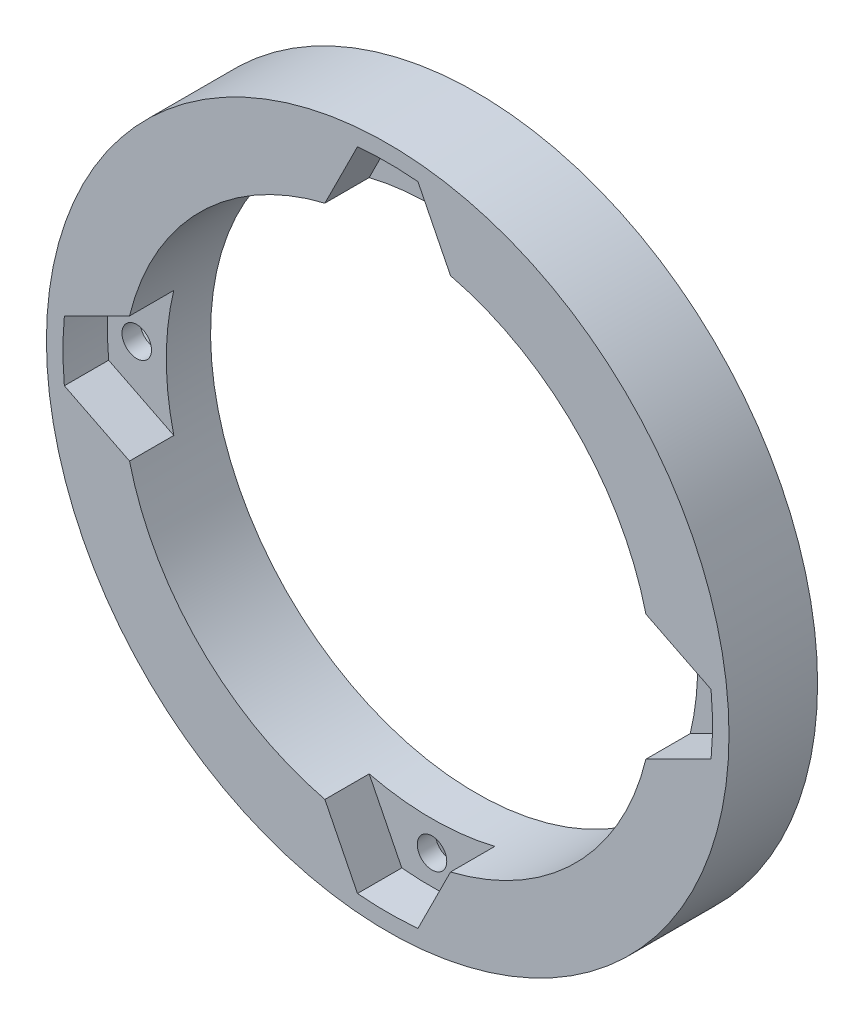
from build123d import *

# Parameters (mm, degrees)
SKETCH2_R           = 73.406
SKETCH2_R_2         = 57.15
BOSS_EXTRUDE1_DEPTH = 19.05
CUT_EXTRUDE5_DEPTH  = 9.525
SKETCH9_R           = 3.175
CUT_EXTRUDE6_DEPTH  = 9.525
CUT_EXTRUDE7_DEPTH  = 5.588


with BuildPart() as part:
    # Sketch2 → Boss-Extrude1 (new body)
    with BuildSketch(Plane.XY):
        Circle(SKETCH2_R)
        Circle(SKETCH2_R_2, mode=Mode.SUBTRACT)
    extrude(amount=BOSS_EXTRUDE1_DEPTH)

    # Sketch7 → Cut-Extrude5 (cut)
    with BuildSketch(Plane.XY.offset(19.05)):
        with BuildLine():
            Line((-69.546757065, 6.501621467), (-55.530220399, 13.5098898))
            ThreePointArc((-55.530220399, 13.5098898), (-57.15, 0), (-55.530220399, -13.5098898))
            Line((-55.530220399, -13.5098898), (-69.546757065, -6.501621467))
            ThreePointArc((-69.546757065, -6.501621467), (-69.85, 0), (-69.546757065, 6.501621467))
        make_face()
        with BuildLine():
            Line((6.501621467, 69.546757065), (13.5098898, 55.530220399))
            ThreePointArc((13.5098898, 55.530220399), (0, 57.15), (-13.5098898, 55.530220399))
            Line((-13.5098898, 55.530220399), (-6.501621467, 69.546757065))
            ThreePointArc((-6.501621467, 69.546757065), (0, 69.85), (6.501621467, 69.546757065))
        make_face()
        with BuildLine():
            Line((69.546757065, -6.501621467), (55.530220399, -13.5098898))
            ThreePointArc((55.530220399, -13.5098898), (57.15, 0), (55.530220399, 13.5098898))
            Line((55.530220399, 13.5098898), (69.546757065, 6.501621467))
            ThreePointArc((69.546757065, 6.501621467), (69.85, 0), (69.546757065, -6.501621467))
        make_face()
        with BuildLine():
            Line((-6.501621467, -69.546757065), (-13.5098898, -55.530220399))
            ThreePointArc((-13.5098898, -55.530220399), (0, -57.15), (13.5098898, -55.530220399))
            Line((13.5098898, -55.530220399), (6.501621467, -69.546757065))
            ThreePointArc((6.501621467, -69.546757065), (0, -69.85), (-6.501621467, -69.546757065))
        make_face()
    extrude(amount=-CUT_EXTRUDE5_DEPTH, mode=Mode.SUBTRACT)

    # Sketch9 → Cut-Extrude6 (cut)
    with BuildSketch(Plane.XY.offset(9.525)):
        with Locations((-63.5, 0)):
            Circle(SKETCH9_R)
        with Locations((0, 63.5)):
            Circle(SKETCH9_R)
        with Locations((63.5, 0)):
            Circle(SKETCH9_R)
        with Locations((0, -63.5)):
            Circle(SKETCH9_R)
    extrude(amount=-CUT_EXTRUDE6_DEPTH, mode=Mode.SUBTRACT)

    # Sketch10 → Cut-Extrude7 (cut)
    with BuildSketch(Plane(origin=(0, 0, 0), x_dir=(-1, 0, 0), z_dir=(0, 0, -1))):
        Polygon((-6.30581964, 63.5), (-3.15290982, 58.039), (3.15290982, 58.039), (6.30581964, 63.5), (3.15290982, 68.961), (-3.15290982, 68.961), align=None)
        Polygon((-63.5, -6.30581964), (-58.039, -3.15290982), (-58.039, 3.15290982), (-63.5, 6.30581964), (-68.961, 3.15290982), (-68.961, -3.15290982), align=None)
        Polygon((63.5, 6.30581964), (58.039, 3.15290982), (58.039, -3.15290982), (63.5, -6.30581964), (68.961, -3.15290982), (68.961, 3.15290982), align=None)
        Polygon((6.30581964, -63.5), (3.15290982, -58.039), (-3.15290982, -58.039), (-6.30581964, -63.5), (-3.15290982, -68.961), (3.15290982, -68.961), align=None)
    extrude(amount=-CUT_EXTRUDE7_DEPTH, mode=Mode.SUBTRACT)


solid = part.part
